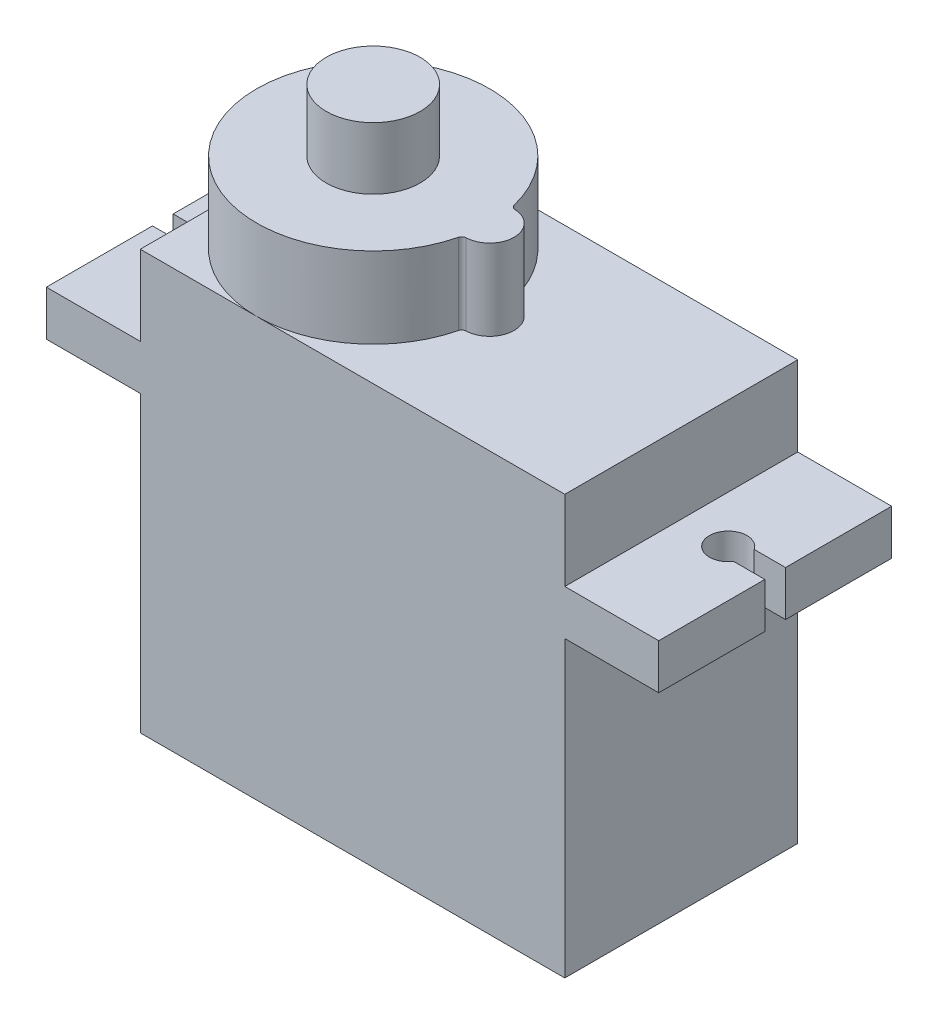
from build123d import *

# Parameters (mm, degrees)
SKETCH1_W             = 22600
SKETCH1_H             = 12400
BOSS_EXTRUDE1_DEPTH   = 22300
SKETCH2_W             = 5000
SKETCH2_H             = 2400
BOSS_EXTRUDE2_DEPTH   = 12400
CUT_EXTRUDE1_DEPTH    = 22300
BOSS_EXTRUDE3_DEPTH   = 4300
SKETCH5_R             = 2500
BOSS_EXTRUDE4_DEPTH   = 3300
SKETCH6_R             = 600
BOSS_EXTRUDE5_DEPTH   = 2300
BOSS_EXTRUDE5_2_DEPTH = 2300
BOSS_EXTRUDE5_3_DEPTH = 2300


with BuildPart() as part:
    # Sketch1 → Boss-Extrude1 (new body)
    with BuildSketch(Plane(origin=(0, 0, 0), x_dir=(1, 0, 0), z_dir=(0, 1, 0))):
        Rectangle(SKETCH1_W, SKETCH1_H)
    extrude(amount=BOSS_EXTRUDE1_DEPTH)

    # Sketch2 → Boss-Extrude2 (add)
    with BuildSketch(Plane.XY.offset(6200)):
        with Locations((13800, 16850)):
            Rectangle(SKETCH2_W, SKETCH2_H)
        with Locations((-13800, 16850)):
            Rectangle(SKETCH2_W, SKETCH2_H)
    extrude(amount=-BOSS_EXTRUDE2_DEPTH)

    # Sketch3 → Cut-Extrude1 (cut)
    with BuildSketch(Plane(origin=(0, 18050, 0), x_dir=(1, 0, 0), z_dir=(0, 1, 0))):
        with BuildLine():
            Line((14635.164654425, 550), (16300, 550))
            Line((16300, 550), (16300, -550))
            Line((16300, -550), (14635.164654425, -550))
            ThreePointArc((14635.164654425, -550), (12800, 0), (14635.164654425, 550))
        make_face()
        with BuildLine():
            Line((-16300, 550), (-16300, -550))
            Line((-16300, -550), (-14635.164654425, -550))
            ThreePointArc((-14635.164654425, -550), (-12800, 0), (-14635.164654425, 550))
            Line((-14635.164654425, 550), (-16300, 550))
        make_face()
    extrude(amount=-CUT_EXTRUDE1_DEPTH, mode=Mode.SUBTRACT)

    # Sketch4 → Boss-Extrude3 (add)
    with BuildSketch(Plane(origin=(0, 22300, 0), x_dir=(1, 0, 0), z_dir=(0, 1, 0))):
        with BuildLine():
            ThreePointArc((918.604651163, 1488.757217615), (-11300, 0), (918.604651163, -1488.757217615))
            ThreePointArc((918.604651163, -1488.757217615), (1003.329596305, -1355.013632202), (1151.404786681, -1298.983274683))
            ThreePointArc((1151.404786681, -1298.983274683), (2400, 0), (1151.404786681, 1298.983274683))
            ThreePointArc((1151.404786681, 1298.983274683), (1003.329596305, 1355.013632202), (918.604651163, 1488.757217615))
        make_face()
    extrude(amount=BOSS_EXTRUDE3_DEPTH)

    # Sketch5 → Boss-Extrude4 (add)
    with BuildSketch(Plane(origin=(0, 26600, 0), x_dir=(1, 0, 0), z_dir=(0, 1, 0))):
        with Locations((-5100, 0)):
            Circle(SKETCH5_R)
    extrude(amount=BOSS_EXTRUDE4_DEPTH)


with BuildPart() as body_2:
    # Sketch6 → Boss-Extrude5 (new body)
    with BuildSketch(Plane.ZY.offset(11300)):
        with Locations((0, 4500)):
            Circle(SKETCH6_R)
    extrude(amount=BOSS_EXTRUDE5_DEPTH)


with BuildPart() as body_3:
    # Sketch6 → Boss-Extrude5 2 (new body)
    with BuildSketch(Plane.ZY.offset(11300)):
        with Locations((1199.999759082, 4499.239603738)):
            Circle(SKETCH6_R)
    extrude(amount=BOSS_EXTRUDE5_2_DEPTH)


with BuildPart() as body_4:
    # Sketch6 → Boss-Extrude5 3 (new body)
    with BuildSketch(Plane.ZY.offset(11300)):
        with Locations((-1199.999755032, 4499.233238809)):
            Circle(SKETCH6_R)
    extrude(amount=BOSS_EXTRUDE5_3_DEPTH)


solid = Compound([part.part, body_2.part, body_3.part, body_4.part])
